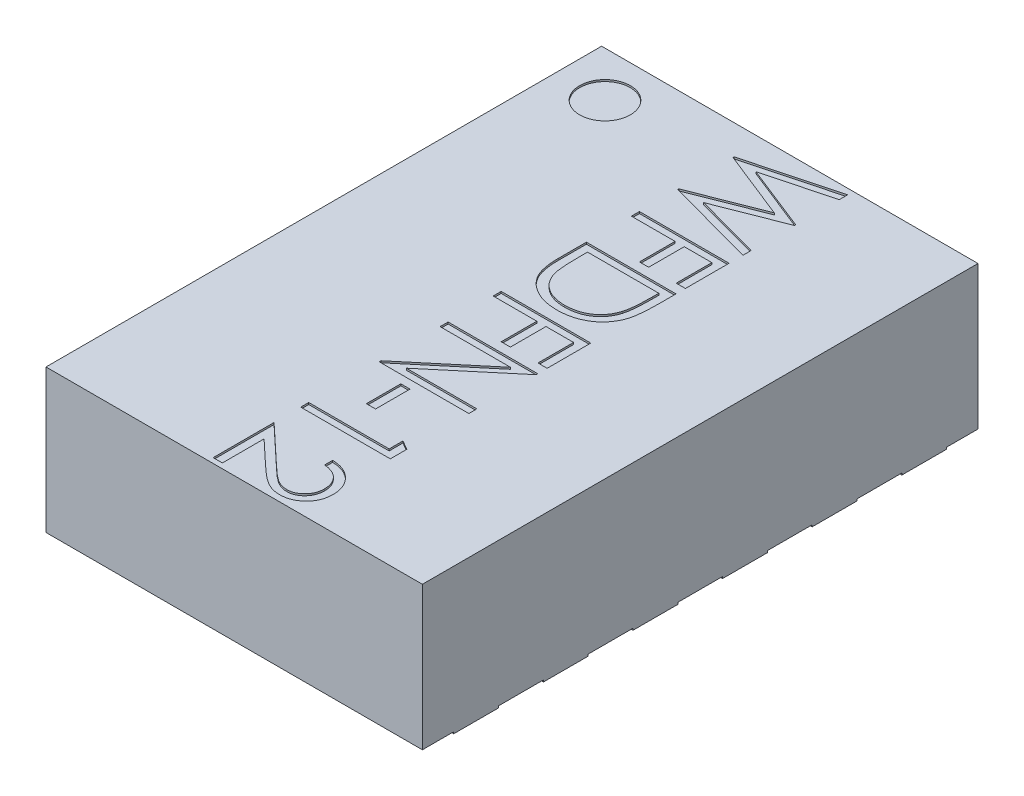
from build123d import *

# Parameters (mm, degrees)
SKETCH1_W           = 2.1
SKETCH1_H           = 3.1
BOSS_EXTRUDE1_DEPTH = 0.8
SKETCH2_W           = 0.3
SKETCH2_H           = 0.25
BOSS_EXTRUDE2_DEPTH = 0.01
SKETCH3_R           = 0.141484285
SKETCH3_W           = 0.051282051
SKETCH3_H           = 0.192307692
CUT_EXTRUDE1_DEPTH  = 0.01


with BuildPart() as part:
    # Sketch1 → Boss-Extrude1 (new body)
    with BuildSketch(Plane(origin=(0, 0, 0), x_dir=(1, 0, 0), z_dir=(0, 1, 0))):
        Rectangle(SKETCH1_W, SKETCH1_H)
    extrude(amount=BOSS_EXTRUDE1_DEPTH)

    # Sketch2 → Boss-Extrude2 (add)
    with BuildSketch(Plane.XZ):
        with Locations((-0.9, -1.25)):
            Rectangle(SKETCH2_W, SKETCH2_H)
        with Locations((-0.9, -0.75)):
            Rectangle(SKETCH2_W, SKETCH2_H)
        with Locations((-0.9, -0.25)):
            Rectangle(SKETCH2_W, SKETCH2_H)
        with Locations((-0.9, 0.25)):
            Rectangle(SKETCH2_W, SKETCH2_H)
        with Locations((-0.9, 0.75)):
            Rectangle(SKETCH2_W, SKETCH2_H)
        with Locations((-0.9, 1.25)):
            Rectangle(SKETCH2_W, SKETCH2_H)
        with Locations((0.9, 1.25)):
            Rectangle(SKETCH2_W, SKETCH2_H)
        with Locations((0.9, 0.75)):
            Rectangle(SKETCH2_W, SKETCH2_H)
        with Locations((0.9, 0.25)):
            Rectangle(SKETCH2_W, SKETCH2_H)
        with Locations((0.9, -0.25)):
            Rectangle(SKETCH2_W, SKETCH2_H)
        with Locations((0.9, -0.75)):
            Rectangle(SKETCH2_W, SKETCH2_H)
        with Locations((0.9, -1.25)):
            Rectangle(SKETCH2_W, SKETCH2_H)
        Polygon((-0.5, 0), (-0.5, -1.125), (-0.273064281, -1.325), (0.5, -1.325), (0.5, 1.325), (-0.5, 1.325), align=None)
    extrude(amount=BOSS_EXTRUDE2_DEPTH)

    # Sketch3 → Cut-Extrude1 (cut)
    with BuildSketch(Plane(origin=(0, 0.8, 0), x_dir=(1, 0, 0), z_dir=(0, 1, 0))):
        with Locations((-0.779313797, 1.298184183)):
            Circle(SKETCH3_R)
        Polygon((0.354538739, 1.517948718), (0.354538739, 1.471574519), (-0.01214796, 1.373717949), (0.354538739, 1.228185096), (0.354538739, 1.221674679), (-0.009643953, 1.078846154), (0.354538739, 0.980488782), (0.354538739, 0.934615385), (-0.145461261, 1.06943109), (-0.145461261, 1.075841346), (0.236950598, 1.226282051), (-0.145461261, 1.378525641), (-0.145461261, 1.384935897), align=None)
        Polygon((0.354538739, 0.856588097), (0.354538739, 0.612998353), (0.303256688, 0.612998353), (0.303256688, 0.811716302), (0.149410534, 0.811716302), (0.149410534, 0.612998353), (0.098128483, 0.612998353), (0.098128483, 0.811716302), (-0.145461261, 0.811716302), (-0.145461261, 0.856588097), align=None)
        with BuildLine():
            Line((-0.145461261, 0.560612092), (0.354538739, 0.560612092))
            Line((0.354538739, 0.560612092), (0.354538739, 0.459650553))
            add(Edge.make_bspline(
                [(0.354538739, 0.459650553), (0.354475687, 0.450869251), (0.354353871, 0.43390382), (0.353577079, 0.409388001), (0.352216807, 0.386736959), (0.350197191, 0.365963559), (0.347773086, 0.347034425), (0.34469023, 0.329979875), (0.341064581, 0.314772271), (0.337972229, 0.305419512), (0.336509893, 0.300996707)],
                knots=[0, 0, 0, 0, 2.6344e-05, 5.0896e-05, 7.3576e-05, 9.4406e-05, 0.000113501, 0.000130809, 0.00014638, 0.00016035, 0.00016035, 0.00016035, 0.00016035], degree=3))
            add(Edge.make_bspline(
                [(0.336509893, 0.300996707), (0.334305504, 0.295211748), (0.329946714, 0.283773013), (0.321724421, 0.267486228), (0.31240813, 0.252154232), (0.301986357, 0.237693623), (0.290161038, 0.224439091), (0.277445523, 0.211856266), (0.263320219, 0.20051), (0.248264724, 0.189944961), (0.232126306, 0.180700379), (0.215232502, 0.172547732), (0.197614921, 0.165586795), (0.179145334, 0.160155347), (0.160001048, 0.155668046), (0.140037141, 0.152657173), (0.119369997, 0.150657173), (0.105344893, 0.150457164), (0.098228643, 0.150355681)],
                knots=[0, 0, 0, 0, 1.8562e-05, 3.6703e-05, 5.4637e-05, 7.2347e-05, 9.0089e-05, 0.000107867, 0.000125951, 0.000144372, 0.000162995, 0.000181675, 0.00020061, 0.000219749, 0.000239381, 0.000259553, 0.000280274, 0.000301616, 0.000301616, 0.000301616, 0.000301616], degree=3))
            add(Edge.make_bspline(
                [(0.098228643, 0.150355681), (0.092048487, 0.150445594), (0.079869844, 0.150622777), (0.061920846, 0.152211813), (0.044505714, 0.154525883), (0.027700935, 0.15809214), (0.011393305, 0.16247421), (-0.004339735, 0.167883036), (-0.019509716, 0.174293018), (-0.033993068, 0.181729884), (-0.047765832, 0.189861768), (-0.060591001, 0.198777902), (-0.072712494, 0.20796665), (-0.083583569, 0.218136521), (-0.093825977, 0.2285867), (-0.102886303, 0.239871339), (-0.111159209, 0.251622792), (-0.118584306, 0.264067408), (-0.125026401, 0.277503468), (-0.130545228, 0.292114356), (-0.135089429, 0.307978322), (-0.138886825, 0.325071052), (-0.141897412, 0.343426038), (-0.143915602, 0.363060116), (-0.145280268, 0.38394346), (-0.145399759, 0.398283353), (-0.145461261, 0.405664175)],
                knots=[0, 0, 0, 0, 1.8536e-05, 3.6528e-05, 5.4022e-05, 7.121e-05, 8.8024e-05, 0.000104653, 0.00012108, 0.000137385, 0.000153463, 0.000169021, 0.000184227, 0.000199043, 0.000213636, 0.00022809, 0.0002424, 0.000256726, 0.000271509, 0.000287042, 0.000303525, 0.000320972, 0.000339546, 0.00035929, 0.000380164, 0.000402303, 0.000402303, 0.000402303, 0.000402303], degree=3))
            Line((-0.145461261, 0.405664175), (-0.145461261, 0.560612092))
        make_face()
        with BuildLine():
            Line((-0.09417921, 0.515740297), (-0.09417921, 0.45834847))
            add(Edge.make_bspline(
                [(-0.09417921, 0.45834847), (-0.094143767, 0.45010156), (-0.094075599, 0.434239731), (-0.093477427, 0.411431446), (-0.092500007, 0.390591532), (-0.091132139, 0.371717031), (-0.089322337, 0.354818599), (-0.087304493, 0.33986092), (-0.084790572, 0.326893026), (-0.082511863, 0.319045964), (-0.081458857, 0.315419784)],
                knots=[0, 0, 0, 0, 2.474e-05, 4.7585e-05, 6.8442e-05, 8.7325e-05, 0.000104347, 0.000119419, 0.000132599, 0.000143923, 0.000143923, 0.000143923, 0.000143923], degree=3))
            add(Edge.make_bspline(
                [(-0.081458857, 0.315419784), (-0.079851611, 0.310855636), (-0.076675509, 0.301836354), (-0.070879825, 0.288854737), (-0.064023063, 0.276741445), (-0.056356322, 0.265294385), (-0.047760866, 0.254587682), (-0.038210679, 0.244668833), (-0.027811379, 0.235467341), (-0.016524009, 0.227083861), (-0.004421545, 0.21959278), (0.008341938, 0.213063473), (0.021735637, 0.207523453), (0.035807826, 0.203018616), (0.050545239, 0.199527626), (0.065909106, 0.197043828), (0.081904221, 0.195499728), (0.092783046, 0.195319402), (0.098328803, 0.195227476)],
                knots=[0, 0, 0, 0, 1.4513e-05, 2.868e-05, 4.2582e-05, 5.6222e-05, 6.9971e-05, 8.3714e-05, 9.748e-05, 0.000111583, 0.000125842, 0.000140131, 0.000154547, 0.000169276, 0.000184411, 0.000199939, 0.000215935, 0.000232569, 0.000232569, 0.000232569, 0.000232569], degree=3))
            add(Edge.make_bspline(
                [(0.098328803, 0.195227476), (0.104176408, 0.195300881), (0.11566408, 0.195445086), (0.13252039, 0.197254594), (0.148730113, 0.199904544), (0.16430492, 0.203716292), (0.179224546, 0.208640742), (0.193573283, 0.214533245), (0.207166474, 0.221687668), (0.22011925, 0.229787232), (0.232235448, 0.238880476), (0.243373122, 0.248927062), (0.253553017, 0.259821056), (0.262791342, 0.27151225), (0.270923806, 0.284164108), (0.278158319, 0.297562534), (0.284305192, 0.311896264), (0.287573361, 0.321869694), (0.289234252, 0.326938213)],
                knots=[0, 0, 0, 0, 1.7535e-05, 3.4448e-05, 5.0799e-05, 6.6784e-05, 8.2494e-05, 9.7895e-05, 0.000113262, 0.000128518, 0.000143683, 0.000158647, 0.000173457, 0.000188365, 0.000203284, 0.00021852, 0.000234, 0.000249995, 0.000249995, 0.000249995, 0.000249995], degree=3))
            add(Edge.make_bspline(
                [(0.289234252, 0.326938213), (0.290393742, 0.331131234), (0.292859135, 0.340046747), (0.295548474, 0.354595242), (0.297920545, 0.370968835), (0.299928836, 0.389240221), (0.301369882, 0.409388572), (0.302451499, 0.431429385), (0.303181018, 0.455372185), (0.303230833, 0.47196969), (0.303256688, 0.480584047)],
                knots=[0, 0, 0, 0, 1.3046e-05, 2.7739e-05, 4.434e-05, 6.2679e-05, 8.2867e-05, 0.00010493, 0.000128879, 0.000154721, 0.000154721, 0.000154721, 0.000154721], degree=3))
            Line((0.303256688, 0.480584047), (0.303256688, 0.515740297))
            Line((0.303256688, 0.515740297), (-0.09417921, 0.515740297))
        make_face(mode=Mode.SUBTRACT)
        Polygon((0.354538739, 0.085148907), (0.354538739, -0.158440837), (0.303256688, -0.158440837), (0.303256688, 0.040277112), (0.149410534, 0.040277112), (0.149410534, -0.158440837), (0.098128483, -0.158440837), (0.098128483, 0.040277112), (-0.145461261, 0.040277112), (-0.145461261, 0.085148907), align=None)
        Polygon((-0.145461261, -0.210827099), (0.354538739, -0.210827099), (0.354538739, -0.220242163), (-0.038990908, -0.550570689), (0.354538739, -0.550570689), (0.354538739, -0.595442484), (-0.145461261, -0.595442484), (-0.145461261, -0.585226137), (0.247166944, -0.255698894), (-0.145461261, -0.255698894), align=None)
        with Locations((0.046846432, -0.737572335)):
            Rectangle(SKETCH3_W, SKETCH3_H)
        Polygon((0.354538739, -0.941100424), (0.354538739, -1.033548341), (-0.145461261, -1.033548341), (-0.145461261, -0.988676546), (0.303256688, -0.988676546), (0.303256688, -0.911753469), align=None)
        with BuildLine():
            Line((0.200692585, -1.246191013), (0.200692585, -1.201319218))
            add(Edge.make_bspline(
                [(0.200692585, -1.201319218), (0.206645599, -1.201611619), (0.218337158, -1.202185886), (0.235383015, -1.204876346), (0.251678061, -1.208722493), (0.267082595, -1.214173382), (0.281780637, -1.220904752), (0.295577014, -1.229145898), (0.308608654, -1.238721131), (0.320628825, -1.249612884), (0.331616764, -1.261431441), (0.341205823, -1.274105989), (0.349214945, -1.287506258), (0.355946796, -1.30151602), (0.360993733, -1.316297302), (0.364740122, -1.331708811), (0.366993765, -1.347820205), (0.367236037, -1.358797339), (0.367359252, -1.364380115)],
                knots=[0, 0, 0, 0, 1.7869e-05, 3.5094e-05, 5.1686e-05, 6.8032e-05, 8.4031e-05, 0.000100109, 0.000116155, 0.000132467, 0.000148698, 0.000164503, 0.000180049, 0.000195461, 0.000211045, 0.000226811, 0.000242988, 0.000259729, 0.000259729, 0.000259729, 0.000259729], degree=3))
            add(Edge.make_bspline(
                [(0.367359252, -1.364380115), (0.367230901, -1.369862697), (0.366978696, -1.380635775), (0.364812835, -1.39635892), (0.361420607, -1.411327105), (0.356661262, -1.425511072), (0.350263487, -1.438797652), (0.342578124, -1.451286659), (0.333689577, -1.463126775), (0.323224746, -1.473784887), (0.312052977, -1.483571755), (0.300126134, -1.492014934), (0.287807664, -1.499245386), (0.275003636, -1.505272198), (0.261593489, -1.509708789), (0.24777246, -1.513077104), (0.233397487, -1.514981021), (0.223667979, -1.515273224), (0.218721432, -1.515421782)],
                knots=[0, 0, 0, 0, 1.6441e-05, 3.2306e-05, 4.7516e-05, 6.2435e-05, 7.7085e-05, 9.1652e-05, 0.000106376, 0.000121393, 0.000136374, 0.000150882, 0.000165157, 0.000179183, 0.000193247, 0.000207458, 0.000221808, 0.000236648, 0.000236648, 0.000236648, 0.000236648], degree=3))
            add(Edge.make_bspline(
                [(0.218721432, -1.515421782), (0.211757455, -1.515179887), (0.19795171, -1.514700343), (0.177663873, -1.510598289), (0.15800767, -1.504191645), (0.142188055, -1.496477737), (0.129440414, -1.488695959), (0.118944884, -1.481683458), (0.107644103, -1.473474199), (0.095575912, -1.463948699), (0.082645783, -1.453304003), (0.068861526, -1.441443694), (0.054365559, -1.428283197), (0.044464759, -1.419046268), (0.039334412, -1.414259923)],
                knots=[0, 0, 0, 0, 2.0874e-05, 4.1382e-05, 6.1843e-05, 8.2763e-05, 9.3997e-05, 0.000106637, 0.000120621, 0.000135888, 0.000152753, 0.000170863, 0.000190435, 0.000211484, 0.000211484, 0.000211484, 0.000211484], degree=3))
            Line((0.039334412, -1.414259923), (-0.09417921, -1.289159763))
            Line((-0.09417921, -1.289159763), (-0.09417921, -1.521832039))
            Line((-0.09417921, -1.521832039), (-0.145461261, -1.521832039))
            Line((-0.145461261, -1.521832039), (-0.145461261, -1.182088449))
            Line((-0.145461261, -1.182088449), (0.061469829, -1.375998705))
            add(Edge.make_bspline(
                [(0.061469829, -1.375998705), (0.06639789, -1.380720166), (0.075863686, -1.389789126), (0.089687645, -1.402610811), (0.102497264, -1.41414527), (0.114349306, -1.424400153), (0.125176581, -1.433383899), (0.135063939, -1.441067764), (0.143926529, -1.44748571), (0.15433793, -1.454287394), (0.167064721, -1.460773251), (0.182539291, -1.466473656), (0.198504376, -1.469924604), (0.20928984, -1.470340692), (0.214715021, -1.470549987)],
                knots=[0, 0, 0, 0, 2.0474e-05, 3.9327e-05, 5.6561e-05, 7.2184e-05, 8.6342e-05, 9.8763e-05, 0.000109743, 0.000119161, 0.000136049, 0.000152462, 0.000168531, 0.000184794, 0.000184794, 0.000184794, 0.000184794], degree=3))
            add(Edge.make_bspline(
                [(0.214715021, -1.470549987), (0.218127027, -1.4704601), (0.224851434, -1.470282949), (0.23470399, -1.468689892), (0.24424478, -1.466349376), (0.253355839, -1.462741918), (0.262216364, -1.458407689), (0.270556966, -1.452870392), (0.278661958, -1.446542716), (0.286253426, -1.439202922), (0.293208389, -1.431145192), (0.299368841, -1.422631451), (0.30451732, -1.413624366), (0.30873781, -1.404161472), (0.312048581, -1.394269267), (0.314342663, -1.383928588), (0.315783018, -1.373168015), (0.3159779, -1.365820372), (0.316077201, -1.36207643)],
                knots=[0, 0, 0, 0, 1.0229e-05, 2.0159e-05, 2.9876e-05, 3.9641e-05, 4.9496e-05, 5.9414e-05, 6.9613e-05, 8.0309e-05, 9.1032e-05, 0.000101511, 0.000111785, 0.000122097, 0.00013255, 0.000143022, 0.000153831, 0.00016506, 0.00016506, 0.00016506, 0.00016506], degree=3))
            add(Edge.make_bspline(
                [(0.316077201, -1.36207643), (0.315975084, -1.358166293), (0.315774544, -1.350487431), (0.314370868, -1.33921353), (0.311951629, -1.328457523), (0.308634904, -1.318197636), (0.30445912, -1.308423985), (0.299157648, -1.299224943), (0.292937478, -1.290516525), (0.285846823, -1.282314727), (0.277915084, -1.274778561), (0.269182118, -1.268018007), (0.259591115, -1.26225197), (0.24935871, -1.257140637), (0.238212833, -1.253229711), (0.226423576, -1.24988669), (0.213823442, -1.247458231), (0.205142234, -1.246620435), (0.200692585, -1.246191013)],
                knots=[0, 0, 0, 0, 1.1729e-05, 2.3035e-05, 3.4018e-05, 4.4756e-05, 5.5343e-05, 6.5841e-05, 7.6541e-05, 8.7405e-05, 9.8316e-05, 0.000109314, 0.000120463, 0.00013184, 0.000143564, 0.000155836, 0.000168585, 0.000181991, 0.000181991, 0.000181991, 0.000181991], degree=3))
        make_face()
    extrude(amount=-CUT_EXTRUDE1_DEPTH, mode=Mode.SUBTRACT)


solid = part.part
